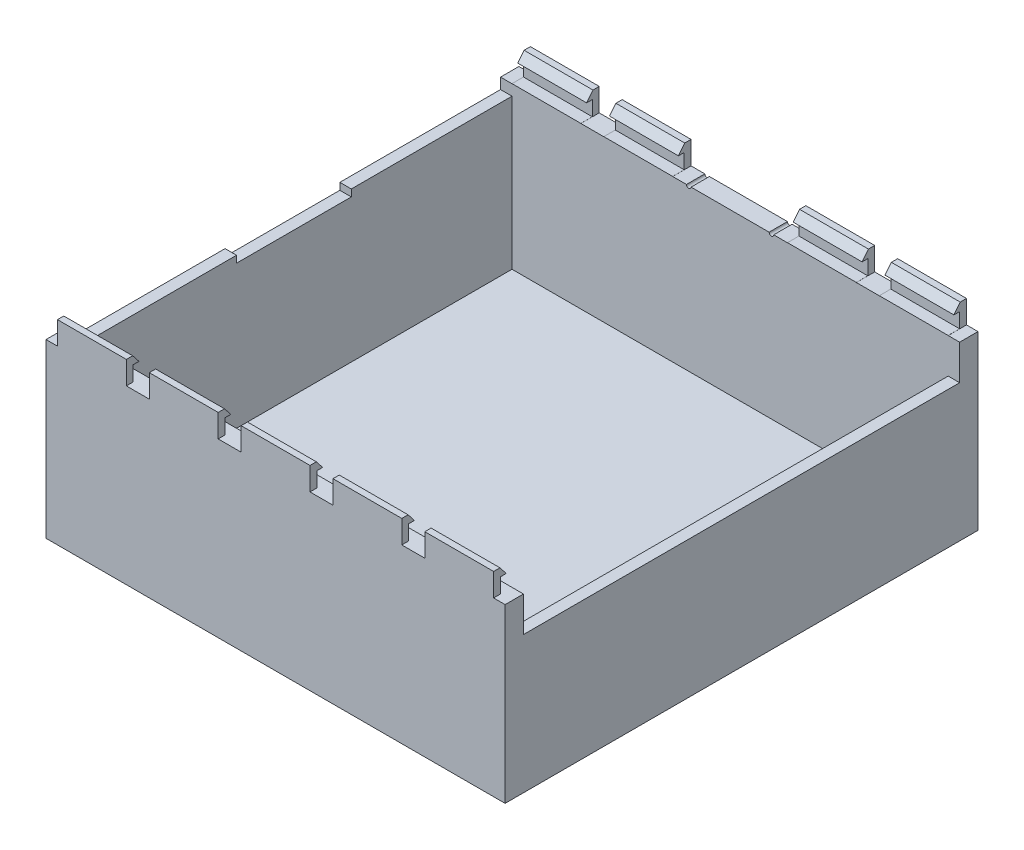
from build123d import *

# Parameters (mm, degrees)
SKETCH_1_W               = 200
SKETCH_1_H               = 206
EXTRUDE_2_DEPTH          = 5
SKETCH_2_W               = 200
SKETCH_2_H               = 8
EXTRUDE_3_DEPTH          = 70
SKETCH_3_W               = 5
SKETCH_3_H               = 190
EXTRUDE_4_DEPTH          = 54.7
SKETCH_4_W               = 200
SKETCH_4_H               = 8
EXTRUDE_5_DEPTH          = 70
SKETCH_14_W              = 5
SKETCH_14_H              = 190
EXTRUDE_7_DEPTH          = 65.3
SKETCH_15_W              = 5
SKETCH_15_H              = 50
CUT_EXTRUDE_7_DEPTH      = 3
CUT_EXTRUDE_8_DEPTH      = 1
CUT_EXTRUDE_8_DEPTH_BACK = 8
CUT_EXTRUDE_9_DEPTH      = 1
CUT_EXTRUDE_9_DEPTH_BACK = 8
SKETCH_19_R              = 1.5
CUT_EXTRUDE_10_DEPTH     = 5
SKETCH_21_W              = 30
SKETCH_21_H              = 8
EXTRUDE_8_DEPTH          = 10
SKETCH_24_W              = 5
SKETCH_24_H              = 6.5
CUT_EXTRUDE_11_DEPTH     = 196
SKETCH_25_W              = 2.5
SKETCH_25_H              = 3.5
CUT_EXTRUDE_12_DEPTH     = 196
CUT_EXTRUDE_13_DEPTH     = 196
SKETCH_27_W              = 5
SKETCH_27_H              = 6.5
CUT_EXTRUDE_14_DEPTH     = 196
SKETCH_28_W              = 2.5
SKETCH_28_H              = 3.467533866
CUT_EXTRUDE_15_DEPTH     = 196
CUT_EXTRUDE_16_DEPTH     = 196


with BuildPart() as part:
    # Эскиз1 → Бобышка-Вытянуть2 (new body)
    with BuildSketch(Plane(origin=(0, 0, 0), x_dir=(1, 0, 0), z_dir=(0, 1, 0))):
        Rectangle(SKETCH_1_W, SKETCH_1_H)
    extrude(amount=EXTRUDE_2_DEPTH)

    # Эскиз2 → Бобышка-Вытянуть3 (add)
    with BuildSketch(Plane(origin=(0, 5, 0), x_dir=(1, 0, 0), z_dir=(0, 1, 0))):
        with Locations((0, -99)):
            Rectangle(SKETCH_2_W, SKETCH_2_H)
    extrude(amount=EXTRUDE_3_DEPTH)

    # Эскиз3 → Бобышка-Вытянуть4 (add)
    with BuildSketch(Plane(origin=(0, 5, 0), x_dir=(1, 0, 0), z_dir=(0, 1, 0))):
        with Locations((97.5, 0)):
            Rectangle(SKETCH_3_W, SKETCH_3_H)
    extrude(amount=EXTRUDE_4_DEPTH)

    # Эскиз4 → Бобышка-Вытянуть5 (add)
    with BuildSketch(Plane(origin=(0, 5, 0), x_dir=(1, 0, 0), z_dir=(0, 1, 0))):
        with Locations((0, 99)):
            Rectangle(SKETCH_4_W, SKETCH_4_H)
    extrude(amount=EXTRUDE_5_DEPTH)

    # Эскиз14 → Бобышка-Вытянуть7 (add)
    with BuildSketch(Plane(origin=(0, 5, 0), x_dir=(1, 0, 0), z_dir=(0, 1, 0))):
        with Locations((-97.5, 0)):
            Rectangle(SKETCH_14_W, SKETCH_14_H)
    extrude(amount=EXTRUDE_7_DEPTH)

    # Эскиз15 → Вырез-Вытянуть7 (cut)
    with BuildSketch(Plane(origin=(0, 70.3, 0), x_dir=(1, 0, 0), z_dir=(0, 1, 0))):
        with Locations((-97.5, 0)):
            Rectangle(SKETCH_15_W, SKETCH_15_H)
    extrude(amount=-CUT_EXTRUDE_7_DEPTH, mode=Mode.SUBTRACT)

    # Эскиз16 → Вырез-Вытянуть8 (cut, two sides)
    with BuildSketch(Plane(origin=(0, 0, -103), x_dir=(-1, 0, 0), z_dir=(0, 0, -1))) as cut_extrude_8_sk:
        with BuildLine():
            Line((-19, 366.325434328), (-19, 75))
            ThreePointArc((-19, 75), (-18, 74), (-17, 75))
            Line((-17, 75), (-17, 366.325434328))
            Line((-17, 366.325434328), (-17, 948.976302985))
            Line((-17, 948.976302985), (-19, 948.976302985))
            Line((-19, 948.976302985), (-19, 366.325434328))
        make_face()
    extrude(amount=CUT_EXTRUDE_8_DEPTH, mode=Mode.SUBTRACT)
    extrude(cut_extrude_8_sk.sketch, amount=-CUT_EXTRUDE_8_DEPTH_BACK, mode=Mode.SUBTRACT)

    # Эскиз18 → Вырез-Вытянуть9 (cut, two sides)
    with BuildSketch(Plane(origin=(0, 0, -103), x_dir=(-1, 0, 0), z_dir=(0, 0, -1))) as cut_extrude_9_sk:
        with BuildLine():
            Line((17, 366.325434328), (17, 75))
            ThreePointArc((17, 75), (18, 74), (19, 75))
            Line((19, 75), (19, 366.325434328))
            Line((19, 366.325434328), (19, 948.976302985))
            Line((19, 948.976302985), (17, 948.976302985))
            Line((17, 948.976302985), (17, 366.325434328))
        make_face()
    extrude(amount=CUT_EXTRUDE_9_DEPTH, mode=Mode.SUBTRACT)
    extrude(cut_extrude_9_sk.sketch, amount=-CUT_EXTRUDE_9_DEPTH_BACK, mode=Mode.SUBTRACT)

    # Эскиз19 → Вырез-Вытянуть10 (cut)
    with BuildSketch(Plane(origin=(0, 0, -103), x_dir=(-1, 0, 0), z_dir=(0, 0, -1))):
        with Locations((0, 70)):
            Circle(SKETCH_19_R)
    extrude(amount=-CUT_EXTRUDE_10_DEPTH, mode=Mode.SUBTRACT)

    # Эскиз21 → Бобышка-Вытянуть8 (add)
    with BuildSketch(Plane(origin=(0, 75, 0), x_dir=(1, 0, 0), z_dir=(0, 1, 0))):
        with Locations((-80, -99)):
            Rectangle(SKETCH_21_W, SKETCH_21_H)
        with Locations((-40, -99)):
            Rectangle(SKETCH_21_W, SKETCH_21_H)
        with Locations((0, -99)):
            Rectangle(SKETCH_21_W, SKETCH_21_H)
        with Locations((40, -99)):
            Rectangle(SKETCH_21_W, SKETCH_21_H)
        with Locations((80, -99)):
            Rectangle(SKETCH_21_W, SKETCH_21_H)
        with Locations((80, 99)):
            Rectangle(SKETCH_21_W, SKETCH_21_H)
        with Locations((40, 99)):
            Rectangle(SKETCH_21_W, SKETCH_21_H)
        with Locations((-40, 99)):
            Rectangle(SKETCH_21_W, SKETCH_21_H)
        with Locations((-80, 99)):
            Rectangle(SKETCH_21_W, SKETCH_21_H)
    extrude(amount=EXTRUDE_8_DEPTH)

    # Эскиз24 → Вырез-Вытянуть11 (cut, through all)
    with BuildSketch(Plane(origin=(95, 0, 0), x_dir=(0, 0, -1), z_dir=(1, 0, 0))):
        with Locations((-97.5, 78.25)):
            Rectangle(SKETCH_24_W, SKETCH_24_H)
    extrude(amount=-CUT_EXTRUDE_11_DEPTH, mode=Mode.SUBTRACT)

    # Эскиз25 → Вырез-Вытянуть12 (cut, through all)
    with BuildSketch(Plane(origin=(95, 0, 0), x_dir=(0, 0, -1), z_dir=(1, 0, 0))):
        with Locations((-96.25, 83.25)):
            Rectangle(SKETCH_25_W, SKETCH_25_H)
    extrude(amount=-CUT_EXTRUDE_12_DEPTH, mode=Mode.SUBTRACT)

    # Эскиз26 → Вырез-Вытянуть13 (cut, through all)
    with BuildSketch(Plane(origin=(95, 0, 0), x_dir=(0, 0, -1), z_dir=(1, 0, 0))):
        Polygon((-97.5, 81.5), (-100.25, 85), (-97.5, 85), align=None)
    extrude(amount=-CUT_EXTRUDE_13_DEPTH, mode=Mode.SUBTRACT)

    # Эскиз27 → Вырез-Вытянуть14 (cut, through all)
    with BuildSketch(Plane(origin=(95, 0, 0), x_dir=(0, 0, -1), z_dir=(1, 0, 0))):
        with Locations((97.5, 78.282466134)):
            Rectangle(SKETCH_27_W, SKETCH_27_H)
    extrude(amount=-CUT_EXTRUDE_14_DEPTH, mode=Mode.SUBTRACT)

    # Эскиз28 → Вырез-Вытянуть15 (cut, through all)
    with BuildSketch(Plane(origin=(95, 0, 0), x_dir=(0, 0, -1), z_dir=(1, 0, 0))):
        with Locations((96.25, 83.266233067)):
            Rectangle(SKETCH_28_W, SKETCH_28_H)
    extrude(amount=-CUT_EXTRUDE_15_DEPTH, mode=Mode.SUBTRACT)

    # Эскиз29 → Вырез-Вытянуть16 (cut, through all)
    with BuildSketch(Plane(origin=(95, 0, 0), x_dir=(0, 0, -1), z_dir=(1, 0, 0))):
        Polygon((97.5, 81.532466134), (100.25, 85), (97.5, 85), align=None)
    extrude(amount=-CUT_EXTRUDE_16_DEPTH, mode=Mode.SUBTRACT)


solid = part.part
